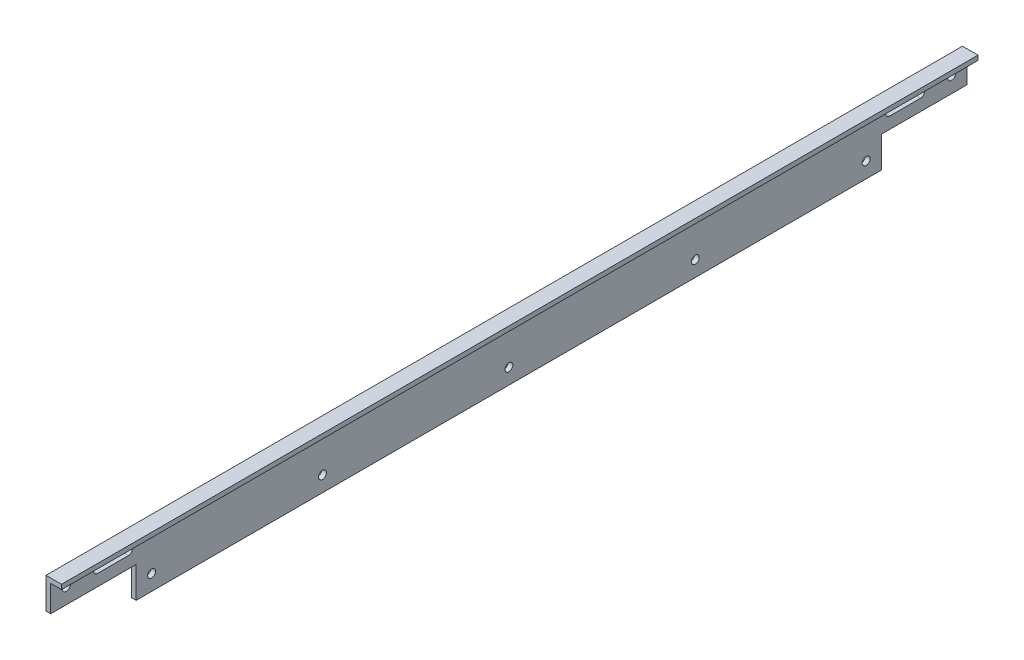
from build123d import *

# Parameters (mm, degrees)
BOSS_EXTRUDE1_DEPTH = 590
CUT_EXTRUDE3_REACH  = 5
SKETCH2_R           = 2.55
CUT_EXTRUDE5_REACH  = 5
SKETCH5_W           = 55
SKETCH5_H           = 20
CUT_EXTRUDE6_REACH  = 12
SKETCH6_R           = 2.55


with BuildPart() as part:
    # Sketch1 → Boss-Extrude1 (new body)
    with BuildSketch(Plane.XY):
        Polygon((0, 0), (0, 40), (10, 40), (10, 37), (3, 37), (3, 0), align=None)
    extrude(amount=BOSS_EXTRUDE1_DEPTH)

    # Sketch2 → Cut-Extrude3 (cut, up to next)
    with BuildSketch(Plane(origin=(3, 0, 0), x_dir=(0, 0, -1), z_dir=(1, 0, 0)), mode=Mode.PRIVATE) as cut_extrude3_sk1:
        with Locations((-525, 10)):
            Circle(SKETCH2_R)
    cut_extrude3_tool1 = extrude(cut_extrude3_sk1.sketch, amount=-CUT_EXTRUDE3_REACH, mode=Mode.PRIVATE) & part.part
    add(cut_extrude3_tool1.solids().sort_by_distance((3, 10, 525))[0], mode=Mode.SUBTRACT)
    # Sketch2 → Cut-Extrude3 (cut, up to next)
    with BuildSketch(Plane(origin=(3, 0, 0), x_dir=(0, 0, -1), z_dir=(1, 0, 0)), mode=Mode.PRIVATE) as cut_extrude3_sk2:
        with Locations((-295, 10)):
            Circle(SKETCH2_R)
    cut_extrude3_tool2 = extrude(cut_extrude3_sk2.sketch, amount=-CUT_EXTRUDE3_REACH, mode=Mode.PRIVATE) & part.part
    add(cut_extrude3_tool2.solids().sort_by_distance((3, 10, 295))[0], mode=Mode.SUBTRACT)
    # Sketch2 → Cut-Extrude3 (cut, up to next)
    with BuildSketch(Plane(origin=(3, 0, 0), x_dir=(0, 0, -1), z_dir=(1, 0, 0)), mode=Mode.PRIVATE) as cut_extrude3_sk3:
        with Locations((-415, 10)):
            Circle(SKETCH2_R)
    cut_extrude3_tool3 = extrude(cut_extrude3_sk3.sketch, amount=-CUT_EXTRUDE3_REACH, mode=Mode.PRIVATE) & part.part
    add(cut_extrude3_tool3.solids().sort_by_distance((3, 10, 415))[0], mode=Mode.SUBTRACT)
    # Sketch2 → Cut-Extrude3 (cut, up to next)
    with BuildSketch(Plane(origin=(3, 0, 0), x_dir=(0, 0, -1), z_dir=(1, 0, 0)), mode=Mode.PRIVATE) as cut_extrude3_sk4:
        with Locations((-175, 10)):
            Circle(SKETCH2_R)
    cut_extrude3_tool4 = extrude(cut_extrude3_sk4.sketch, amount=-CUT_EXTRUDE3_REACH, mode=Mode.PRIVATE) & part.part
    add(cut_extrude3_tool4.solids().sort_by_distance((3, 10, 175))[0], mode=Mode.SUBTRACT)
    # Sketch2 → Cut-Extrude3 (cut, up to next)
    with BuildSketch(Plane(origin=(3, 0, 0), x_dir=(0, 0, -1), z_dir=(1, 0, 0)), mode=Mode.PRIVATE) as cut_extrude3_sk5:
        with Locations((-65, 10)):
            Circle(SKETCH2_R)
    cut_extrude3_tool5 = extrude(cut_extrude3_sk5.sketch, amount=-CUT_EXTRUDE3_REACH, mode=Mode.PRIVATE) & part.part
    add(cut_extrude3_tool5.solids().sort_by_distance((3, 10, 65))[0], mode=Mode.SUBTRACT)

    # Sketch5 → Cut-Extrude5 (cut, up to next)
    with BuildSketch(Plane(origin=(3, 0, 0), x_dir=(0, 0, -1), z_dir=(1, 0, 0)), mode=Mode.PRIVATE) as cut_extrude5_sk1:
        with Locations((-562.5, 10)):
            Rectangle(SKETCH5_W, SKETCH5_H)
    cut_extrude5_tool1 = extrude(cut_extrude5_sk1.sketch, amount=-CUT_EXTRUDE5_REACH, mode=Mode.PRIVATE) & part.part
    add(cut_extrude5_tool1.solids().sort_by_distance((3, 10, 562.5))[0], mode=Mode.SUBTRACT)
    # Sketch5 → Cut-Extrude5 (cut, up to next)
    with BuildSketch(Plane(origin=(3, 0, 0), x_dir=(0, 0, -1), z_dir=(1, 0, 0)), mode=Mode.PRIVATE) as cut_extrude5_sk2:
        with Locations((-27.5, 10)):
            Rectangle(SKETCH5_W, SKETCH5_H)
    cut_extrude5_tool2 = extrude(cut_extrude5_sk2.sketch, amount=-CUT_EXTRUDE5_REACH, mode=Mode.PRIVATE) & part.part
    add(cut_extrude5_tool2.solids().sort_by_distance((3, 10, 27.5))[0], mode=Mode.SUBTRACT)

    # Sketch6 → Cut-Extrude6 (cut, up to next)
    with BuildSketch(Plane.ZY, mode=Mode.PRIVATE) as cut_extrude6_sk1:
        with Locations((10, 30)):
            Circle(SKETCH6_R)
    cut_extrude6_tool1 = extrude(cut_extrude6_sk1.sketch, amount=-CUT_EXTRUDE6_REACH, mode=Mode.PRIVATE) & part.part
    add(cut_extrude6_tool1.solids().sort_by_distance((0, 30, 10))[0], mode=Mode.SUBTRACT)
    # Sketch6 → Cut-Extrude6 (cut, up to next)
    with BuildSketch(Plane.ZY, mode=Mode.PRIVATE) as cut_extrude6_sk2:
        with Locations((580, 30)):
            Circle(SKETCH6_R)
    cut_extrude6_tool2 = extrude(cut_extrude6_sk2.sketch, amount=-CUT_EXTRUDE6_REACH, mode=Mode.PRIVATE) & part.part
    add(cut_extrude6_tool2.solids().sort_by_distance((0, 30, 580))[0], mode=Mode.SUBTRACT)
    # Sketch6 → Cut-Extrude6 (cut, up to next)
    with BuildSketch(Plane.ZY, mode=Mode.PRIVATE) as cut_extrude6_sk3:
        with BuildLine():
            Line((30, 32.55), (50, 32.55))
            ThreePointArc((50, 32.55), (52.55, 30), (50, 27.45))
            Line((50, 27.45), (30, 27.45))
            ThreePointArc((30, 27.45), (27.45, 30), (30, 32.55))
        make_face()
    cut_extrude6_tool3 = extrude(cut_extrude6_sk3.sketch, amount=-CUT_EXTRUDE6_REACH, mode=Mode.PRIVATE) & part.part
    add(cut_extrude6_tool3.solids().sort_by_distance((0, 30, 40))[0], mode=Mode.SUBTRACT)
    # Sketch6 → Cut-Extrude6 (cut, up to next)
    with BuildSketch(Plane.ZY, mode=Mode.PRIVATE) as cut_extrude6_sk4:
        with BuildLine():
            Line((560, 32.55), (540, 32.55))
            ThreePointArc((540, 32.55), (537.45, 30), (540, 27.45))
            Line((540, 27.45), (560, 27.45))
            ThreePointArc((560, 27.45), (562.55, 30), (560, 32.55))
        make_face()
    cut_extrude6_tool4 = extrude(cut_extrude6_sk4.sketch, amount=-CUT_EXTRUDE6_REACH, mode=Mode.PRIVATE) & part.part
    add(cut_extrude6_tool4.solids().sort_by_distance((0, 30, 550))[0], mode=Mode.SUBTRACT)


solid = part.part
